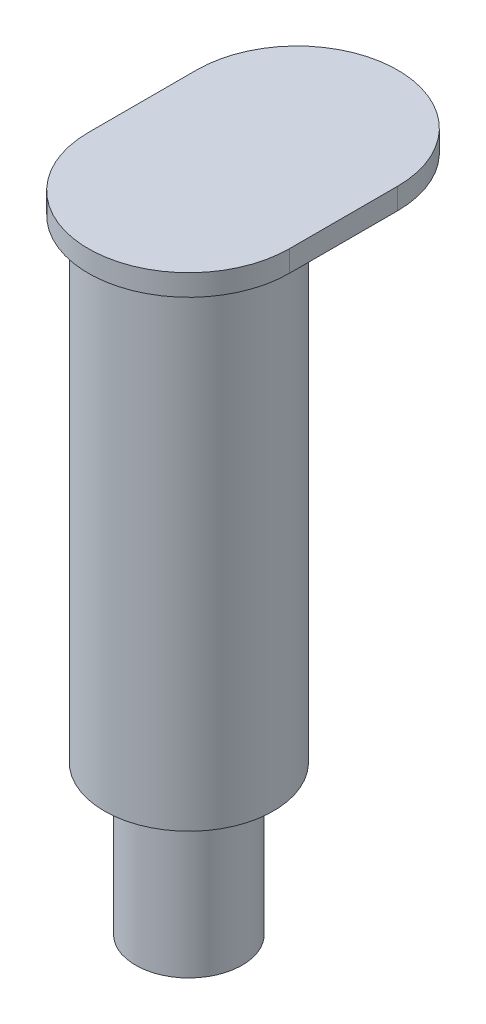
from build123d import *

# Parameters (mm, degrees)
SKETCH1_R           = 15.875
BOSS_EXTRUDE1_DEPTH = 88.9
BOSS_EXTRUDE2_DEPTH = 4
SKETCH3_R           = 9.999999939
BOSS_EXTRUDE3_DEPTH = 27.99999991


with BuildPart() as part:
    # Sketch1 → Boss-Extrude1 (new body)
    with BuildSketch(Plane(origin=(0, 0, 0), x_dir=(1, 0, 0), z_dir=(0, 1, 0))):
        Circle(SKETCH1_R)
    extrude(amount=BOSS_EXTRUDE1_DEPTH)

    # Sketch2 → Boss-Extrude2 (add)
    with BuildSketch(Plane(origin=(0, 88.9, 0), x_dir=(1, 0, 0), z_dir=(0, 1, 0))):
        with BuildLine():
            Line((-18.875, 0), (-18.875, 20.32))
            ThreePointArc((-18.875, 20.32), (0, 39.195), (18.875, 20.32))
            Line((18.875, 20.32), (18.875, 0))
            ThreePointArc((18.875, 0), (0, -18.875), (-18.875, 0))
        make_face()
    extrude(amount=BOSS_EXTRUDE2_DEPTH)

    # Sketch3 → Boss-Extrude3 (add)
    with BuildSketch(Plane.XZ):
        Circle(SKETCH3_R)
    extrude(amount=BOSS_EXTRUDE3_DEPTH)


solid = part.part
